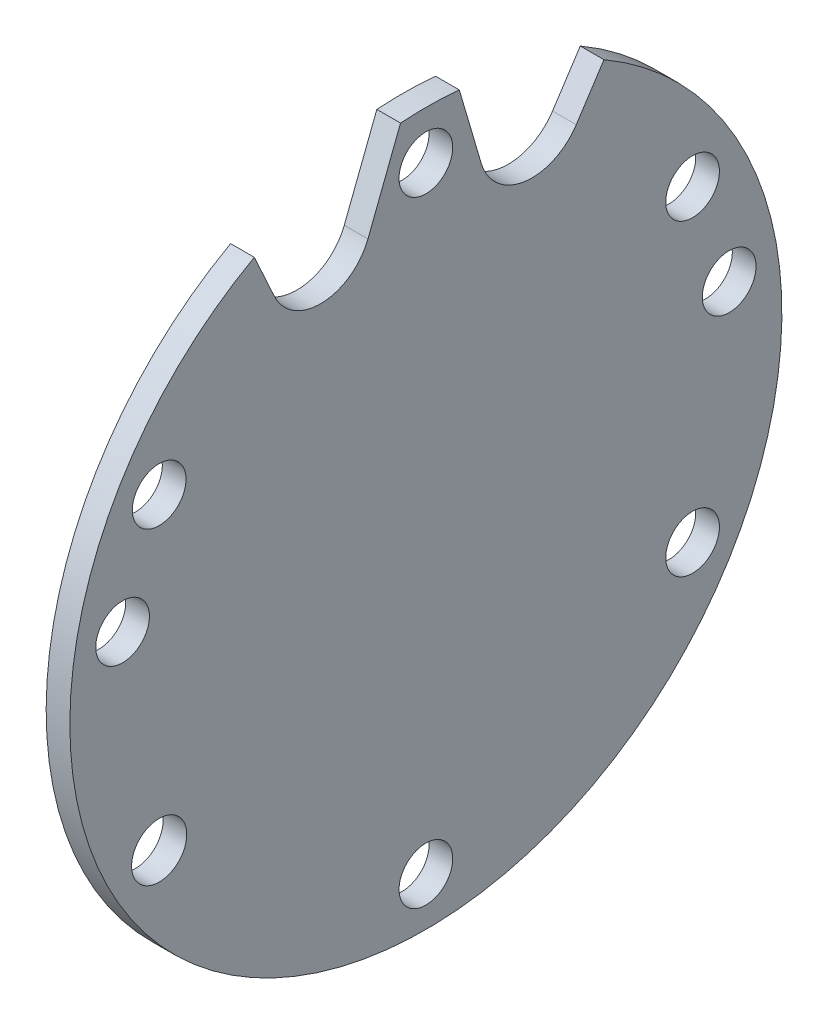
from build123d import *

# Parameters (mm, degrees)
SKETCH1_R           = 3.4
SKETCH1_R_2         = 3.4928829
BOSS_EXTRUDE1_DEPTH = 3


with BuildPart() as part:
    # Sketch1 → Boss-Extrude1 (new body)
    with BuildSketch(Plane(origin=(0, 0, 0), x_dir=(0, 0, -1), z_dir=(1, 0, 0))):
        with BuildLine():
            Line((-21.724666334, 39.505646402), (-19.194616795, 33.971116375))
            ThreePointArc((-19.194616795, 33.971116375), (-13.147904388, 30.212187411), (-7.334597861, 34.322874106))
            Line((-7.334597861, 34.322874106), (-3.211220628, 44.970493516))
            ThreePointArc((-3.211220628, 44.970493516), (0.512740511, 45.08208427), (4.233200317, 44.885824489))
            Line((4.233200317, 44.885824489), (7.016785416, 35.427837599))
            ThreePointArc((7.016785416, 35.427837599), (12.464044741, 30.695847951), (19.042464585, 33.660430978))
            Line((19.042464585, 33.660430978), (22.551822206, 39.039371667))
            ThreePointArc((22.551822206, 39.039371667), (-0.474762826, -45.082500211), (-21.724666334, 39.505646402))
        make_face()
        with Locations((0, 39)):
            Circle(SKETCH1_R, mode=Mode.SUBTRACT)
        with Locations((33.774990748, 19.5)):
            Circle(SKETCH1_R, mode=Mode.SUBTRACT)
        with Locations((38.407502368, 6.772278929)):
            Circle(SKETCH1_R, mode=Mode.SUBTRACT)
        with Locations((33.774990748, -19.5)):
            Circle(SKETCH1_R, mode=Mode.SUBTRACT)
        with Locations((0, -39)):
            Circle(SKETCH1_R, mode=Mode.SUBTRACT)
        with Locations((-33.774990748, -19.5)):
            Circle(SKETCH1_R_2, mode=Mode.SUBTRACT)
        with Locations((-38.407502367, 6.772278929)):
            Circle(SKETCH1_R, mode=Mode.SUBTRACT)
        with Locations((-33.774990748, 19.5)):
            Circle(SKETCH1_R, mode=Mode.SUBTRACT)
    extrude(amount=BOSS_EXTRUDE1_DEPTH)


solid = part.part
